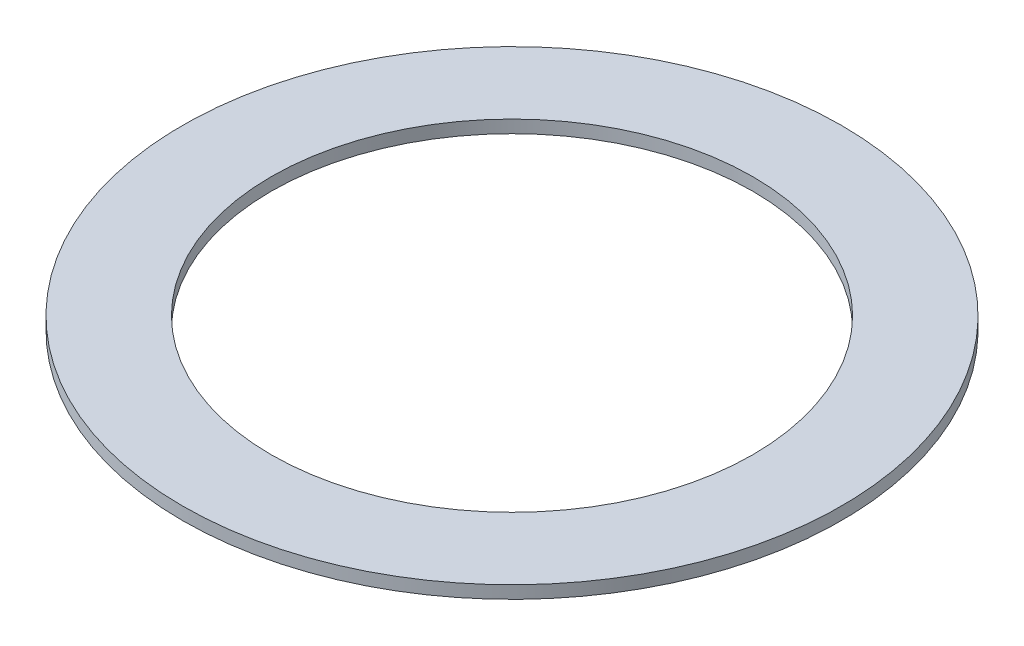
from build123d import *

# Parameters (mm, degrees)
SKETCH1_R           = 13
SKETCH1_R_2         = 9.5
BOSS_EXTRUDE1_DEPTH = 0.5


with BuildPart() as part:
    # Sketch1 → Boss-Extrude1 (new body)
    with BuildSketch(Plane(origin=(0, 0, 0), x_dir=(1, 0, 0), z_dir=(0, 1, 0))):
        Circle(SKETCH1_R)
        Circle(SKETCH1_R_2, mode=Mode.SUBTRACT)
    extrude(amount=BOSS_EXTRUDE1_DEPTH)


solid = part.part
